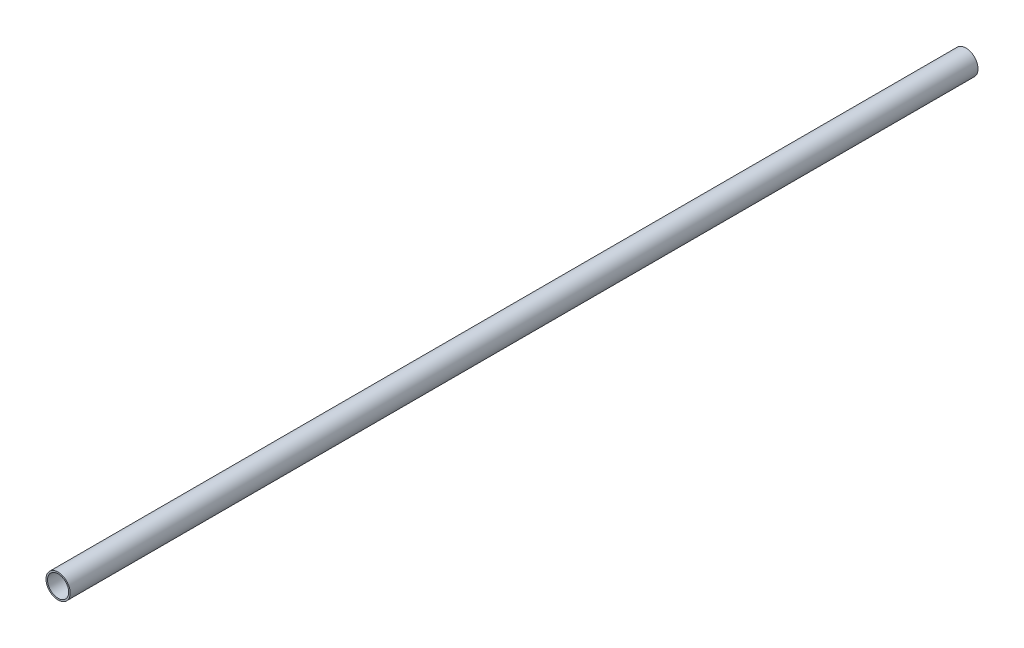
from build123d import *

# Parameters (mm, degrees)
SKETCH1_R           = 4
SKETCH1_R_2         = 3.5
BOSS_EXTRUDE1_DEPTH = 300


with BuildPart() as part:
    # Sketch1 → Boss-Extrude1 (new body)
    with BuildSketch(Plane.XY):
        Circle(SKETCH1_R)
        Circle(SKETCH1_R_2, mode=Mode.SUBTRACT)
    extrude(amount=BOSS_EXTRUDE1_DEPTH)


solid = part.part
